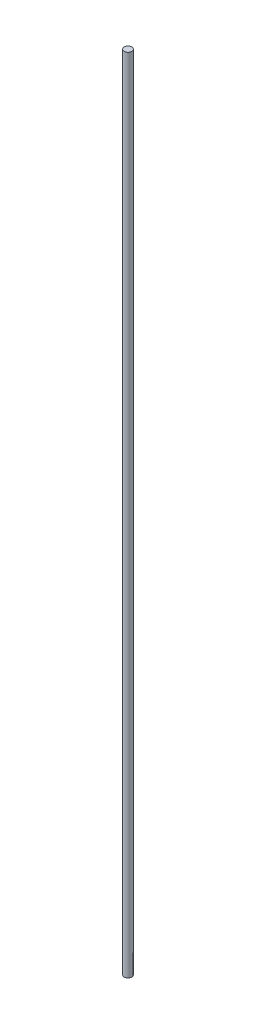
from build123d import *

# Parameters (mm, degrees)
BOSS_EXTRUDE1_DEPTH      = 330.2
BOSS_EXTRUDE1_DEPTH_BACK = 330.2
SKETCH1_R                = 3.175


with BuildPart() as part:
    # Sketch1 → Boss-Extrude1 (new, two sides: drawn at the far end of the back side and taken through both)
    with BuildSketch(Plane(origin=(0, 0, 0), x_dir=(1, 0, 0), z_dir=(0, 1, 0)).offset(-BOSS_EXTRUDE1_DEPTH_BACK)):
        Circle(SKETCH1_R)
    extrude(amount=BOSS_EXTRUDE1_DEPTH + BOSS_EXTRUDE1_DEPTH_BACK)


solid = part.part
